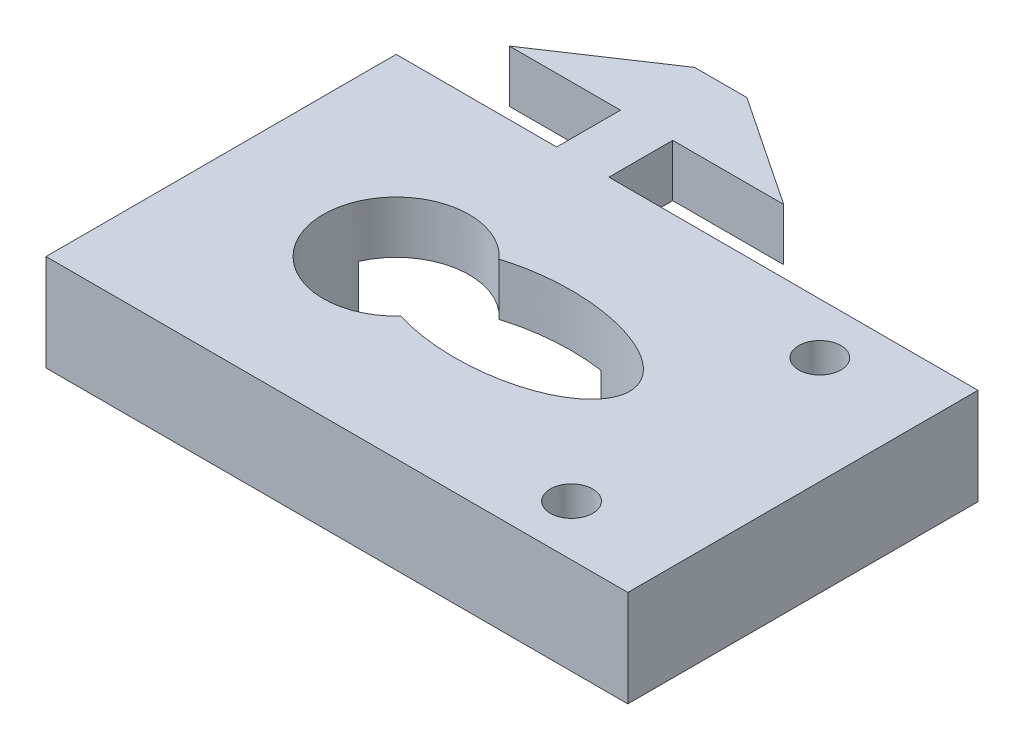
from build123d import *

# Parameters (mm, degrees)
BOSS_EXTRUDE1_DEPTH      = 3.5814
BOSS_EXTRUDE2_DEPTH      = 3.035
BOSS_EXTRUDE2_DEPTH_BACK = 3.035
SKETCH7_W                = 39.878
SKETCH7_H                = 24
CUT_EXTRUDE3_DEPTH       = 39.2533866
CUT_EXTRUDE3_DEPTH_BACK  = 39.2533866
SKETCH5_R                = 1.45
SKETCH8_W                = 18.796
SKETCH8_H                = 3.035
CUT_EXTRUDE4_DEPTH       = 10


with BuildPart() as part:
    # Sketch1 → Boss-Extrude1 (new body)
    with BuildSketch(Plane(origin=(0, 0, 0), x_dir=(1, 0, 0), z_dir=(0, 1, 0))):
        Polygon((-9.398, 2.1874988), (-1.7907, 2.1874988), (-1.7907, -2.1874988), (-12.79, -2.1874988), (-12.79, -26.1874988), (27.088, -26.1874988), (27.088, -2.1874988), (1.7907, -2.1874988), (1.7907, 2.1874988), (9.398, 2.1874988), (1.7907, 7.2674988), (-1.7907, 7.2674988), align=None)
    extrude(amount=BOSS_EXTRUDE1_DEPTH)

    # Sketch7 → Boss-Extrude2 (add, two sides: drawn at the far end of the back side and taken through both)
    with BuildSketch(Plane(origin=(0, 0, 0), x_dir=(1, 0, 0), z_dir=(0, 1, 0)).offset(-BOSS_EXTRUDE2_DEPTH_BACK)):
        with Locations((7.149, -14.1874988)):
            Rectangle(SKETCH7_W, SKETCH7_H)
    extrude(amount=BOSS_EXTRUDE2_DEPTH + BOSS_EXTRUDE2_DEPTH_BACK)

    # Sketch5 → Cut-Extrude3 (cut, two sides: drawn at the far end of the back side and taken through both)
    with BuildSketch(Plane(origin=(0, 3.5814, 0), x_dir=(1, 0, 0), z_dir=(0, 1, 0)).offset(-CUT_EXTRUDE3_DEPTH_BACK)):
        with BuildLine():
            ThreePointArc((2.902928009, -10.816700272), (-5.79, -14.1874988), (2.902928009, -17.558297328))
            add(Edge.make_bspline(
                [(2.902928009, -17.558297328), (15.21, -21.489668828), (15.21, -14.1874988)],
                knots=[1.002278043, 1.002278043, 1.002278043, 3.141592654, 3.141592654, 3.141592654], degree=2, weights=[1, 0.480424813, 1]))
            add(Edge.make_bspline(
                [(15.21, -14.1874988), (15.21, -6.885328772), (2.902928009, -10.816700272)],
                knots=[3.141592654, 3.141592654, 3.141592654, 5.280907265, 5.280907265, 5.280907265], degree=2, weights=[1, 0.480424813, 1]))
        make_face()
        with Locations((19.738, -22.6964988)):
            Circle(SKETCH5_R)
        with Locations((19.738, -5.6784988)):
            Circle(SKETCH5_R)
    extrude(amount=CUT_EXTRUDE3_DEPTH + CUT_EXTRUDE3_DEPTH_BACK, mode=Mode.SUBTRACT)

    # Sketch8 → Cut-Extrude4 (cut)
    with BuildSketch(Plane(origin=(0, 0, 2.1874988), x_dir=(-1, 0, 0), z_dir=(0, 0, -1))):
        with Locations((0, -1.5175)):
            Rectangle(SKETCH8_W, SKETCH8_H)
    extrude(amount=-CUT_EXTRUDE4_DEPTH, mode=Mode.SUBTRACT)


solid = part.part
